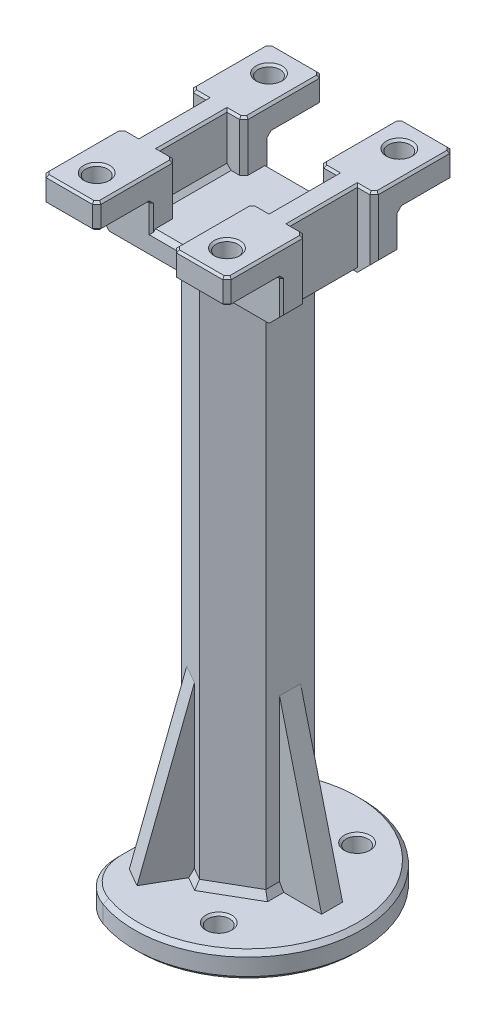
from build123d import *
from OCP.BRepFilletAPI import BRepFilletAPI_MakeChamfer

# Parameters (mm, degrees)
SKETCH3_R           = 27
BOSS_EXTRUDE1_DEPTH = 6
BOSS_EXTRUDE2_DEPTH = 126
CUT_EXTRUDE5_REACH  = 133.659
SKETCH13_R          = 2.6
BOSS_EXTRUDE3_DEPTH = 14
SKETCH10_W          = 4
SKETCH10_H          = 16
CUT_EXTRUDE3_DEPTH  = 12
CUT_EXTRUDE4_REACH  = 145.185
SKETCH11_W          = 4
SKETCH11_H          = 16
SKETCH12_W          = 13
SKETCH12_H          = 13
BOSS_EXTRUDE4_DEPTH = 6
CUT_EXTRUDE1_REACH  = 156.784
SKETCH7_R           = 2.6
CUT_EXTRUDE6_REACH  = 150.977
SKETCH19_W          = 10
SKETCH19_H          = 41.952353926
RIB3_REACH          = 156.784
SKETCH18_WALL_W     = 352.798496404
SKETCH18_WALL_H     = 5
CIRPATTERN1_COUNT   = 3
FILLET1_R           = 12
CHAMFER1_SIZE       = 4
CHAMFER2_SIZE       = 1
CHAMFER2_SIZE2      = 1.732050808
CHAMFER3_SIZE       = 1
CHAMFER4_SIZE       = 0.5


with BuildPart() as part:
    # Sketch3 → Boss-Extrude1 (new body)
    with BuildSketch(Plane(origin=(0, 0, 0), x_dir=(1, 0, 0), z_dir=(0, 1, 0))):
        with Locations(Location((0, 0, 0), (0, 0, 270))):
            Circle(SKETCH3_R)
    extrude(amount=BOSS_EXTRUDE1_DEPTH)

    # Sketch4 → Boss-Extrude2 (add)
    with BuildSketch(Plane(origin=(0, 6, 0), x_dir=(1, 0, 0), z_dir=(0, 1, 0))):
        Polygon((10, -5.773502692), (10, 5.773502692), (0, 11.547005384), (-10, 5.773502692), (-10, -5.773502692), (0, -11.547005384), align=None)
    extrude(amount=BOSS_EXTRUDE2_DEPTH)

    # Sketch13 → Cut-Extrude5 (cut, up to next)
    with BuildSketch(Plane(origin=(0, 6, 0), x_dir=(1, 0, 0), z_dir=(0, 1, 0)), mode=Mode.PRIVATE) as cut_extrude5_sk1:
        with Locations(Location((9.5, 16.454482672, 0), (0, 0, 270))):
            Circle(SKETCH13_R)
    cut_extrude5_tool1 = extrude(cut_extrude5_sk1.sketch, amount=-CUT_EXTRUDE5_REACH, mode=Mode.PRIVATE) & part.part
    # Sketch13 → Cut-Extrude5 (cut, up to next)
    with BuildSketch(Plane(origin=(0, 6, 0), x_dir=(1, 0, 0), z_dir=(0, 1, 0)), mode=Mode.PRIVATE) as cut_extrude5_sk2:
        with Locations(Location((9.5, -16.454482672, 0), (0, 0, 270))):
            Circle(SKETCH13_R)
    cut_extrude5_tool2 = extrude(cut_extrude5_sk2.sketch, amount=-CUT_EXTRUDE5_REACH, mode=Mode.PRIVATE) & part.part
    add(cut_extrude5_tool1.solids().sort_by_distance((9.5, 6, -16.454483))[0], mode=Mode.SUBTRACT)
    add(cut_extrude5_tool2.solids().sort_by_distance((9.5, 6, 16.454483))[0], mode=Mode.SUBTRACT)

    # Sketch6 → Boss-Extrude3 (add, symmetric)
    with BuildSketch(Plane.XY):
        Polygon((-22, 150), (-22, 132), (0, 132), (22, 132), (22, 150), (9, 150), (9, 138), (-9, 138), (-9, 150), align=None)
    extrude(amount=BOSS_EXTRUDE3_DEPTH, both=True)

    # Sketch10 → Cut-Extrude3 (cut)
    with BuildSketch(Plane(origin=(0, 150, 0), x_dir=(1, 0, 0), z_dir=(0, 1, 0))):
        with Locations((-20, 0)):
            Rectangle(SKETCH10_W, SKETCH10_H)
        with Locations((-11, 0)):
            Rectangle(SKETCH10_W, SKETCH10_H)
        with Locations((11, 0)):
            Rectangle(SKETCH10_W, SKETCH10_H)
        with Locations((20, 0)):
            Rectangle(SKETCH10_W, SKETCH10_H)
    extrude(amount=-CUT_EXTRUDE3_DEPTH, mode=Mode.SUBTRACT)

    # Sketch11 → Cut-Extrude4 (cut, up to next)
    with BuildSketch(Plane(origin=(0, 138, 0), x_dir=(1, 0, 0), z_dir=(0, 1, 0)), mode=Mode.PRIVATE) as cut_extrude4_sk1:
        with Locations((20, 0)):
            Rectangle(SKETCH11_W, SKETCH11_H)
    cut_extrude4_tool1 = extrude(cut_extrude4_sk1.sketch, amount=-CUT_EXTRUDE4_REACH, mode=Mode.PRIVATE) & part.part
    # Sketch11 → Cut-Extrude4 (cut, up to next)
    with BuildSketch(Plane(origin=(0, 138, 0), x_dir=(1, 0, 0), z_dir=(0, 1, 0)), mode=Mode.PRIVATE) as cut_extrude4_sk2:
        with Locations((-20, 0)):
            Rectangle(SKETCH11_W, SKETCH11_H)
    cut_extrude4_tool2 = extrude(cut_extrude4_sk2.sketch, amount=-CUT_EXTRUDE4_REACH, mode=Mode.PRIVATE) & part.part
    add(cut_extrude4_tool1.solids().sort_by_distance((20, 138, 0))[0], mode=Mode.SUBTRACT)
    add(cut_extrude4_tool2.solids().sort_by_distance((-20, 138, 0))[0], mode=Mode.SUBTRACT)

    # Sketch12 → Boss-Extrude4 (add)
    with BuildSketch(Plane(origin=(0, 150, 0), x_dir=(1, 0, 0), z_dir=(0, 1, 0))):
        with Locations((-15.5, 20.5)):
            Rectangle(SKETCH12_W, SKETCH12_H)
        with Locations((-15.5, -20.5)):
            Rectangle(SKETCH12_W, SKETCH12_H)
        with Locations((15.5, -20.5)):
            Rectangle(SKETCH12_W, SKETCH12_H)
        with Locations((15.5, 20.5)):
            Rectangle(SKETCH12_W, SKETCH12_H)
    extrude(amount=-BOSS_EXTRUDE4_DEPTH)

    # Sketch7 → Cut-Extrude1 (cut, up to next)
    with BuildSketch(Plane(origin=(0, 150, 0), x_dir=(1, 0, 0), z_dir=(0, 1, 0)), mode=Mode.PRIVATE) as cut_extrude1_sk1:
        with Locations(Location((-15.5, 20.5, 0), (0, 0, 270))):
            Circle(SKETCH7_R)
    cut_extrude1_tool1 = extrude(cut_extrude1_sk1.sketch, amount=-CUT_EXTRUDE1_REACH, mode=Mode.PRIVATE) & part.part
    # Sketch7 → Cut-Extrude1 (cut, up to next)
    with BuildSketch(Plane(origin=(0, 150, 0), x_dir=(1, 0, 0), z_dir=(0, 1, 0)), mode=Mode.PRIVATE) as cut_extrude1_sk2:
        with Locations(Location((-15.5, -20.5, 0), (0, 0, 270))):
            Circle(SKETCH7_R)
    cut_extrude1_tool2 = extrude(cut_extrude1_sk2.sketch, amount=-CUT_EXTRUDE1_REACH, mode=Mode.PRIVATE) & part.part
    # Sketch7 → Cut-Extrude1 (cut, up to next)
    with BuildSketch(Plane(origin=(0, 150, 0), x_dir=(1, 0, 0), z_dir=(0, 1, 0)), mode=Mode.PRIVATE) as cut_extrude1_sk3:
        with Locations(Location((15.5, -20.5, 0), (0, 0, 270))):
            Circle(SKETCH7_R)
    cut_extrude1_tool3 = extrude(cut_extrude1_sk3.sketch, amount=-CUT_EXTRUDE1_REACH, mode=Mode.PRIVATE) & part.part
    # Sketch7 → Cut-Extrude1 (cut, up to next)
    with BuildSketch(Plane(origin=(0, 150, 0), x_dir=(1, 0, 0), z_dir=(0, 1, 0)), mode=Mode.PRIVATE) as cut_extrude1_sk4:
        with Locations(Location((15.5, 20.5, 0), (0, 0, 270))):
            Circle(SKETCH7_R)
    cut_extrude1_tool4 = extrude(cut_extrude1_sk4.sketch, amount=-CUT_EXTRUDE1_REACH, mode=Mode.PRIVATE) & part.part
    add(cut_extrude1_tool1.solids().sort_by_distance((-15.5, 150, -20.5))[0], mode=Mode.SUBTRACT)
    add(cut_extrude1_tool2.solids().sort_by_distance((-15.5, 150, 20.5))[0], mode=Mode.SUBTRACT)
    add(cut_extrude1_tool3.solids().sort_by_distance((15.5, 150, 20.5))[0], mode=Mode.SUBTRACT)
    add(cut_extrude1_tool4.solids().sort_by_distance((15.5, 150, -20.5))[0], mode=Mode.SUBTRACT)

    # Sketch19 → Cut-Extrude6 (cut, up to next)
    with BuildSketch(Plane(origin=(0, 6, 0), x_dir=(1, 0, 0), z_dir=(0, 1, 0)), mode=Mode.PRIVATE) as cut_extrude6_sk1:
        with Locations((-22, 0)):
            Rectangle(SKETCH19_W, SKETCH19_H)
    cut_extrude6_tool1 = extrude(cut_extrude6_sk1.sketch, amount=-CUT_EXTRUDE6_REACH, mode=Mode.PRIVATE) & part.part
    add(cut_extrude6_tool1.solids().sort_by_distance((-22, 6, 0))[0], mode=Mode.SUBTRACT)

    # Sketch18 wall → Rib3 (add, up to next)
    with BuildSketch(Plane(origin=(15, 26, 0), x_dir=(0.242535625036, -0.970142500145, 0), z_dir=(0.970142500145, 0.242535625036, 0)), mode=Mode.PRIVATE) as rib3_sk1:
        Rectangle(SKETCH18_WALL_W, SKETCH18_WALL_H)
    rib3_tool1 = extrude(rib3_sk1.sketch, amount=-RIB3_REACH, mode=Mode.PRIVATE) - part.part
    rib3 = rib3_tool1.solids().sort_by_distance((15, 26, 0))[0]
    add(rib3)

    # CirPattern1: Rib3 ×3 about axis
    cirpattern1_axis = Axis((0, 0, 0), (0, 1, 0))
    for i in range(1, CIRPATTERN1_COUNT):
        add(rib3.rotate(cirpattern1_axis, i * 360 / CIRPATTERN1_COUNT))

    # Fillet1
    fillet1_edges = [part.edges().sort_by_distance(p)[0] for p in [
        (-17, 3, -20.976176963),
        (-17, 3, 20.976176963),
    ]]
    fillet(fillet1_edges, radius=FILLET1_R)

    # Chamfer1
    chamfer1_edges = [part.edges().sort_by_distance(p)[0] for p in [
        (22, 132, -11),
        (-22, 132, -11),
        (-22, 132, 11),
        (22, 132, 11),
    ]]
    chamfer(chamfer1_edges, length=CHAMFER1_SIZE)

    # Chamfer2: one chamfer whose edges measure the first distance from different faces: ONE call of the kernel's chamfer builder (chamfer() names one face for all edges)
    chamfer2_edges_1 = [part.edges().sort_by_distance(p)[0] for p in [
        (10, 132, 0),
        (5, 132, -8.660254038),
        (-5, 132, -8.660254038),
        (-10, 132, 0),
        (-5, 132, 8.660254038),
        (5, 132, 8.660254038),
    ]]
    chamfer2_side_1 = [part.faces().sort_by_distance(p)[0] for p in [
        (0, 132, 13.54392983),
    ]]
    chamfer2_edges_2 = [part.edges().sort_by_distance(p)[0] for p in [
        (10, 6, -4.136751346),
        (-1.417468245, 6, 10.728629711),
        (-8.582531755, 6, -6.591878365),
        (5, 6, 8.660254038),
        (10, 6, 4.136751346),
        (5, 6, -8.660254038),
        (-1.417468245, 6, -10.728629711),
        (-10, 6, 0),
        (-8.582531755, 6, 6.591878365),
    ]]
    chamfer2_side_2 = [part.faces().sort_by_distance(p)[0] for p in [
        (26.303437009, 6, 0),
    ]]
    chamfer2 = BRepFilletAPI_MakeChamfer(part.part.solid().wrapped)
    for e in chamfer2_edges_1:
        chamfer2.Add(CHAMFER2_SIZE, CHAMFER2_SIZE2, e.wrapped, chamfer2_side_1[0].wrapped)  # the first distance lies on this face
    for e in chamfer2_edges_2:
        chamfer2.Add(CHAMFER2_SIZE, CHAMFER2_SIZE2, e.wrapped, chamfer2_side_2[0].wrapped)  # the first distance lies on this face
    add(Compound.cast(chamfer2.Shape()), mode=Mode.REPLACE)

    # Chamfer3
    chamfer3_edges = [part.edges().sort_by_distance(p)[0] for p in [
        (18, 132, 0),
        (-18, 132, 0),
        (-22, 147, -27),
        (-9, 147, -27),
        (-22, 147, 27),
        (-9, 147, 27),
        (9, 147, 27),
        (22, 147, 27),
        (9, 147, -27),
        (22, 147, -27),
        (0, 138, -14),
        (-17, 6, 0),
        (0, 138, 14),
        (-17, 0, 0),
        (27, 6, 0),
        (-14.797958971, 6, -21.070338854),
        (-14.797958971, 6, 21.070338854),
        (27, 0, 0),
        (-14.797958971, 0, -21.070338854),
        (-14.797958971, 0, 21.070338854),
        (22, 143, -8),
        (0, 132, -14),
        (0, 132, 14),
        (-22, 143, -8),
        (-22, 143, 8),
        (22, 143, 8),
        (-13, 138, 0),
        (-9, 144, 8),
        (-9, 144, -8),
        (13, 138, 0),
        (9, 144, -8),
        (9, 144, 8),
    ]]
    chamfer(chamfer3_edges, length=CHAMFER3_SIZE)

    # Chamfer4
    chamfer4_edges = [part.edges().sort_by_distance(p)[0] for p in [
        (-22, 140, -14),
        (-9, 144, -20),
        (-15.5, 144, -14),
        (-22, 140, 14),
        (-22, 144, 20),
        (-15.5, 144, 14),
        (9, 140.5, 14),
        (9, 144, 20),
        (15.5, 144, 14),
        (9, 140.5, -14),
        (22, 144, -20),
        (15.5, 144, -14),
        (15.5, 150, -23.1),
        (15.5, 144, -23.1),
        (15.5, 150, 17.9),
        (15.5, 144, 17.9),
        (-15.5, 150, 17.9),
        (-15.5, 144, 17.9),
        (-15.5, 150, -23.1),
        (-15.5, 144, -23.1),
        (9.5, 6, -19.054482672),
        (9.5, 0, -19.054482672),
        (9.5, 6, 13.854482672),
        (9.5, 0, 13.854482672),
        (-9, 140.5, -14),
        (-9, 140.5, 14),
        (22, 140, -14),
        (22, 140, 14),
        (-11.5, 150, -8),
        (11.5, 150, 8),
        (9, 150, 17.5),
        (15.5, 150, 27),
        (22, 150, 17.5),
        (19.5, 150, -8),
        (22, 150, -17.5),
        (15.5, 150, -27),
        (9, 150, -17.5),
        (21.5, 150, -26.5),
        (9.5, 150, -26.5),
        (9.5, 150, 26.5),
        (21.5, 150, 26.5),
        (21.5, 150, 8.5),
        (21.5, 150, -8.5),
        (9.5, 150, -8.5),
        (9.5, 150, 8.5),
        (9, 144, -20),
        (-9, 150, 17.5),
        (-9, 144, 20),
        (-19.5, 150, 8),
        (-22, 150, 17.5),
        (-15.5, 150, 27),
        (-9, 150, -17.5),
        (-15.5, 150, -27),
        (-22, 150, -17.5),
        (-9.5, 150, -26.5),
        (-21.5, 150, -26.5),
        (-21.5, 150, -8.5),
        (-21.5, 150, 8.5),
        (-21.5, 150, 26.5),
        (-9.5, 150, 26.5),
        (-9.5, 150, -8.5),
        (-9.5, 150, 8.5),
        (22, 144, 20),
        (15.5, 144, 27),
        (9.5, 144, 26.5),
        (21.5, 144, 26.5),
        (-15.5, 144, 27),
        (-21.5, 144, 26.5),
        (-9.5, 144, 26.5),
        (-22, 144, -20),
        (-15.5, 144, -27),
        (-9.5, 144, -26.5),
        (-21.5, 144, -26.5),
        (15.5, 144, -27),
        (21.5, 144, -26.5),
        (9.5, 144, -26.5),
        (-18, 150, 0),
        (-19.5, 150, -8),
        (-13, 150, 0),
        (-11.5, 150, 8),
        (13, 150, 0),
        (11.5, 150, -8),
        (18, 150, 0),
        (19.5, 150, 8),
    ]]
    chamfer(chamfer4_edges, length=CHAMFER4_SIZE)


solid = part.part
